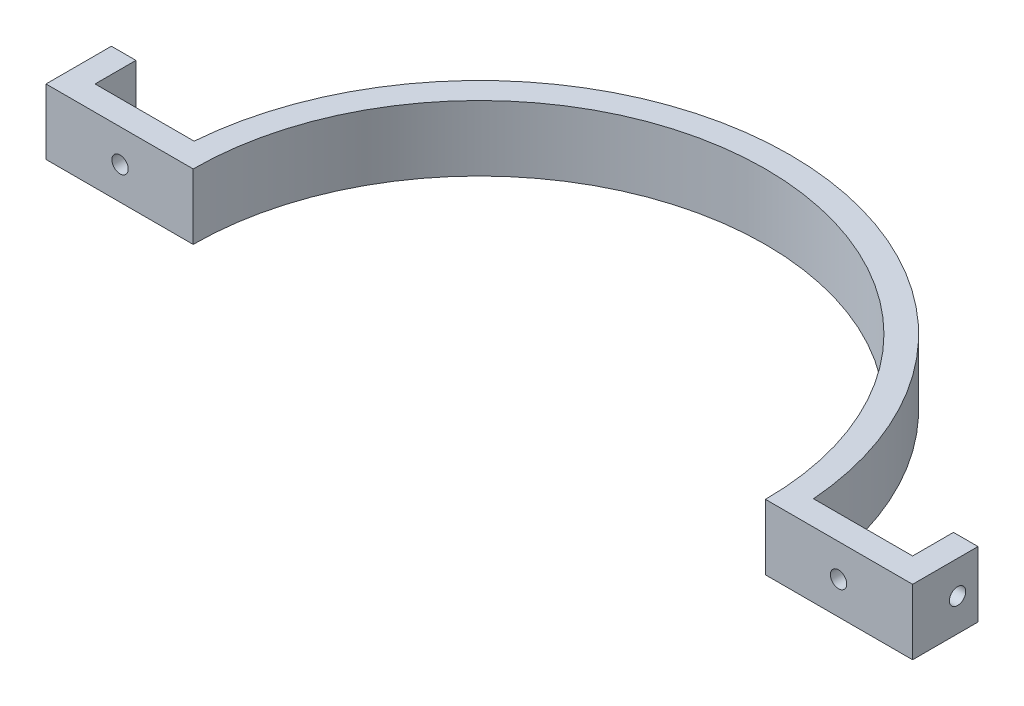
from build123d import *

# Parameters (mm, degrees)
BOSS_EXTRUDE1_DEPTH = 12.7
SKETCH5_R           = 1.5875
CUT_EXTRUDE1_DEPTH  = 5.7625
SKETCH6_R           = 1.5875
CUT_EXTRUDE2_DEPTH  = 5.7625


with BuildPart() as part:
    # Sketch1 → Boss-Extrude1 (new body)
    with BuildSketch(Plane(origin=(0, 0, 0), x_dir=(1, 0, 0), z_dir=(0, 1, 0))):
        with BuildLine():
            Line((-55.5625, 0), (-84.1375, 0))
            Line((-84.1375, 0), (-84.1375, 12.7))
            Line((-84.1375, 12.7), (-79.375, 12.7))
            Line((-79.375, 12.7), (-79.375, 4.7625))
            Line((-79.375, 4.7625), (-60.136712736, 4.7625))
            ThreePointArc((-60.136712736, 4.7625), (0, 60.325), (60.136712736, 4.7625))
            Line((60.136712736, 4.7625), (79.375, 4.7625))
            Line((79.375, 4.7625), (79.375, 12.7))
            Line((79.375, 12.7), (84.1375, 12.7))
            Line((84.1375, 12.7), (84.1375, 0))
            Line((84.1375, 0), (55.5625, 0))
            ThreePointArc((55.5625, 0), (0, 55.5625), (-55.5625, 0))
        make_face()
    extrude(amount=BOSS_EXTRUDE1_DEPTH)

    # Sketch5 → Cut-Extrude1 (cut, through all)
    with BuildSketch(Plane(origin=(0, 0, -4.7625), x_dir=(-1, 0, 0), z_dir=(0, 0, -1))):
        with Locations((69.755856368, 6.35)):
            Circle(SKETCH5_R)
    cut_extrude1 = extrude(amount=-CUT_EXTRUDE1_DEPTH, mode=Mode.SUBTRACT)

    # Sketch6 → Cut-Extrude2 (cut, through all)
    with BuildSketch(Plane(origin=(-79.375, 0, 0), x_dir=(0, 0, -1), z_dir=(1, 0, 0))):
        with Locations((8.73125, 6.35)):
            Circle(SKETCH6_R)
    cut_extrude2 = extrude(amount=-CUT_EXTRUDE2_DEPTH, mode=Mode.SUBTRACT)

    # Mirror2: Cut-Extrude1, Cut-Extrude2 across plane
    add(cut_extrude1.mirror(Plane(origin=(0, 0, 0), x_dir=(0, 0, 1), z_dir=(1, 0, 0))), mode=Mode.SUBTRACT)
    add(cut_extrude2.mirror(Plane(origin=(0, 0, 0), x_dir=(0, 0, 1), z_dir=(1, 0, 0))), mode=Mode.SUBTRACT)


solid = part.part
